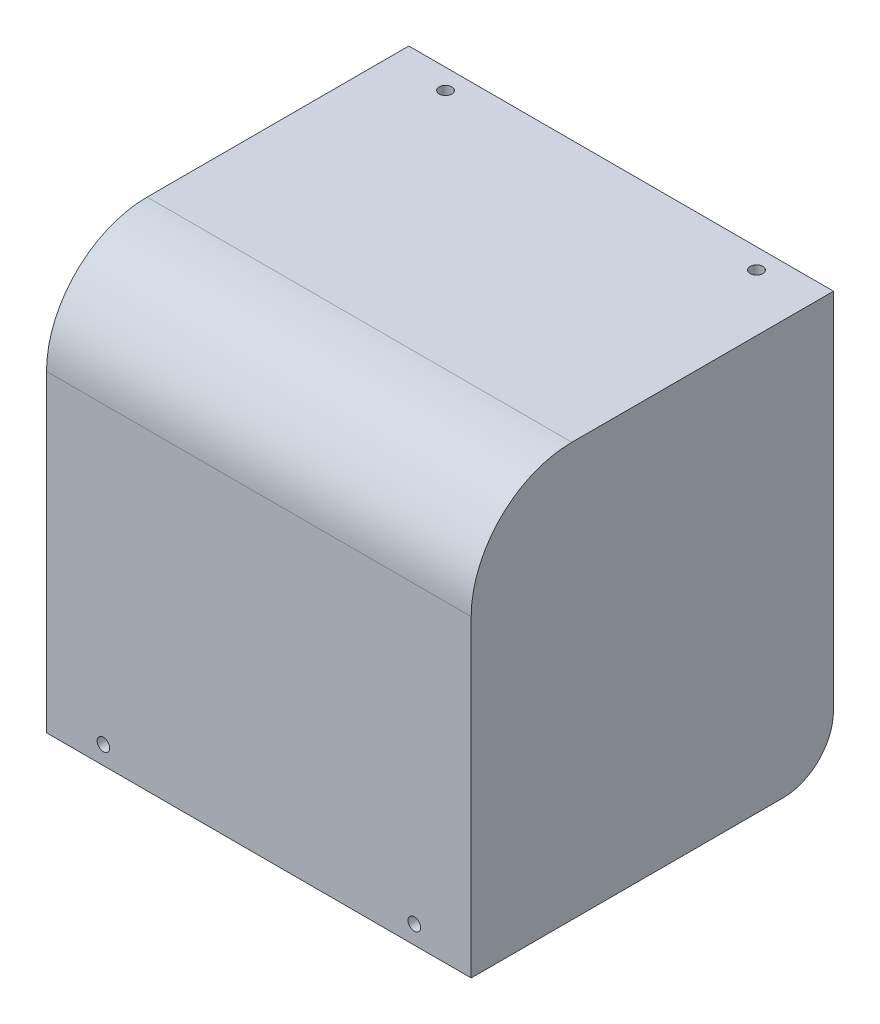
from build123d import *

# Parameters (mm, degrees)
BOSS_EXTRUDE1_DEPTH = 42.2
SKETCH2_R           = 1.25
CUT_EXTRUDE1_DEPTH  = 70
FILLET1_R           = 20
BOSS_EXTRUDE2_DEPTH = 2
FILLET2_R           = 10
SKETCH4_R           = 1.25
CUT_EXTRUDE2_DEPTH  = 10


with BuildPart() as part:
    # Sketch1 → Boss-Extrude1 (new body, symmetric)
    with BuildSketch(Plane(origin=(0, 0, 0), x_dir=(0, 0, -1), z_dir=(1, 0, 0))):
        Polygon((0, 0), (0, 82.2), (72, 82.2), (72, 80.2), (2, 80.2), (2, 0), align=None)
    extrude(amount=BOSS_EXTRUDE1_DEPTH, both=True)

    # Sketch2 → Cut-Extrude1 (cut)
    with BuildSketch(Plane.XY):
        with Locations((-30.9, 3.64)):
            Circle(SKETCH2_R)
        with Locations((30.9, 3.64)):
            Circle(SKETCH2_R)
    extrude(amount=-CUT_EXTRUDE1_DEPTH, mode=Mode.SUBTRACT)

    # Fillet1
    fillet1_edges = [part.edges().sort_by_distance(p)[0] for p in [
        (0, 82.2, 0),
        (0, 80.2, -2),
    ]]
    fillet(fillet1_edges, radius=FILLET1_R)

    # Sketch3 → Boss-Extrude2 (add)
    with BuildSketch(Plane.ZY.offset(42.2)):
        with BuildLine():
            Line((-72, 80.2), (-72, 0))
            Line((-72, 0), (-2, 0))
            Line((-2, 0), (-2, 60.2))
            ThreePointArc((-2, 60.2), (-7.857864376, 74.342135624), (-22, 80.2))
            Line((-22, 80.2), (-72, 80.2))
        make_face()
    boss_extrude2 = extrude(amount=-BOSS_EXTRUDE2_DEPTH)

    # Mirror1: Boss-Extrude2 across plane
    add(boss_extrude2.mirror(Plane(origin=(0, 0, 0), x_dir=(0, 0, 1), z_dir=(1, 0, 0))))

    # Fillet2
    fillet2_edges = [part.edges().sort_by_distance(p)[0] for p in [
        (-41.2, 0, -72),
        (41.2, 0, -72),
    ]]
    fillet(fillet2_edges, radius=FILLET2_R)

    # Sketch4 → Cut-Extrude2 (cut)
    with BuildSketch(Plane(origin=(0, 82.2, 0), x_dir=(1, 0, 0), z_dir=(0, 1, 0))):
        with Locations((-30.9, 68.001968)):
            Circle(SKETCH4_R)
        with Locations((30.9, 68.001968)):
            Circle(SKETCH4_R)
    extrude(amount=-CUT_EXTRUDE2_DEPTH, mode=Mode.SUBTRACT)


solid = part.part
